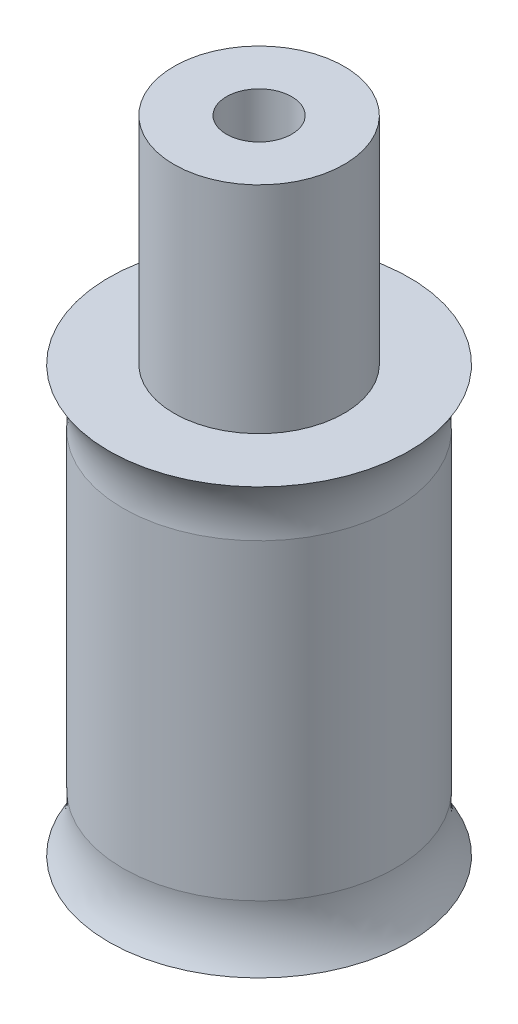
from build123d import *

# Parameters (mm, degrees)
CROQUIS7_R              = 5.3
SALIENTE_EXTRUIR1_DEPTH = 2
CORTAR_EXTRUIR1_START   = 7.6
CROQUIS3_R              = 1.15
CORTAR_EXTRUIR1_DEPTH   = 7.8
CROQUIS4_R              = 2
CORTAR_EXTRUIR2_DEPTH   = 2.6
CORTAR_EXTRUIR4_DEPTH   = 2


with BuildPart() as part:
    # Croquis1 → Revolución2 (revolve)
    with BuildSketch(Plane.XY):
        Polygon((4.8, 15), (3, 15), (3, 22.6), (0, 22.6), (0, 0), (4.8, 0), align=None)
    revolve(axis=Axis((0, 55, 0), (0, -1, 0)))

    # Croquis7 → Saliente-Extruir1 (add)
    with BuildSketch(Plane(origin=(0, 15, 0), x_dir=(1, 0, 0), z_dir=(0, 1, 0))):
        Circle(CROQUIS7_R)
    saliente_extruir1 = extrude(amount=-SALIENTE_EXTRUIR1_DEPTH)

    # Croquis3 → Cortar-Extruir1 (cut)
    with BuildSketch(Plane(origin=(0, 15, 0), x_dir=(1, 0, 0), z_dir=(0, 1, 0)).offset(CORTAR_EXTRUIR1_START)):
        Circle(CROQUIS3_R)
    extrude(amount=-CORTAR_EXTRUIR1_DEPTH, mode=Mode.SUBTRACT)

    # Croquis8 → Cortar-Revolución2 (revolve, cut)
    with BuildSketch(Plane(origin=(0, 0, 0), x_dir=(0, 0, -1), z_dir=(1, 0, 0))):
        with BuildLine():
            Line((5.3, 15), (5.3, 13))
            Line((5.3, 13), (4.8, 13))
            ThreePointArc((4.8, 13), (4.872810183, 14.044297454), (5.3, 15))
        make_face()
    cortar_revoluci_n2 = revolve(axis=Axis((0, 55, 0), (0, -1, 0)), mode=Mode.SUBTRACT)

    # Simetría1: Saliente-Extruir1, Cortar-Revolución2 across plane
    add(saliente_extruir1.mirror(Plane(origin=(0, 7.5, 0), x_dir=(0, 0, 1), z_dir=(0, -1, 0))))
    add(cortar_revoluci_n2.mirror(Plane(origin=(0, 7.5, 0), x_dir=(0, 0, 1), z_dir=(0, -1, 0))), mode=Mode.SUBTRACT)

    # Croquis4 → Cortar-Extruir2 (cut)
    with BuildSketch(Plane.XZ):
        Circle(CROQUIS4_R)
    extrude(amount=-CORTAR_EXTRUIR2_DEPTH, mode=Mode.SUBTRACT)

    # Croquis9 → Cortar-Extruir4 (cut)
    with BuildSketch(Plane.XZ):
        Polygon((-0.4, 3.2), (0, 4), (0.4, 3.2), (0.4, 2.4), (-0.4, 2.4), align=None)
    extrude(amount=-CORTAR_EXTRUIR4_DEPTH, mode=Mode.SUBTRACT)


solid = part.part
